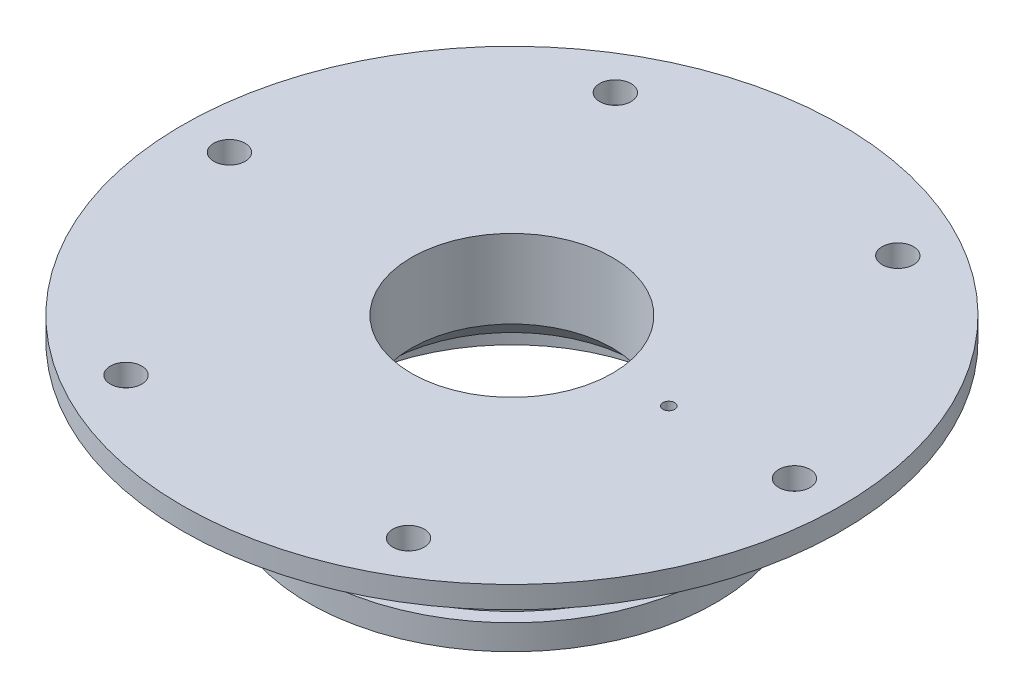
from build123d import *

# Parameters (mm, degrees)
SKETCH1_R                       = 66.675
SKETCH1_R_2                     = 20.32
BOSS_EXTRUDE1_DEPTH             = 4.445
F_1_4_0_25_DIAMETER_HOLE1_D     = 6.35
F_1_4_0_25_DIAMETER_HOLE1_DEPTH = 4.446
CIRPATTERN1_COUNT               = 6
SKETCH6_R                       = 41.148
SKETCH6_R_2                     = 20.32
BOSS_EXTRUDE2_DEPTH             = 25.4
SKETCH9_W                       = 2.9337
SKETCH9_H                       = 5.08
CIRPATTERN2_COUNT               = 6
F_3_32_0_09375_DIAMETER_HOLE1_D = 2.38125
SKETCH13_R                      = 34.925
CUT_EXTRUDE1_DEPTH              = 8.89
CHAMFER2_SIZE                   = 5.08


with BuildPart() as part:
    # Sketch1 → Boss-Extrude1 (new body)
    with BuildSketch(Plane(origin=(0, 0, 0), x_dir=(1, 0, 0), z_dir=(0, 1, 0))):
        Circle(SKETCH1_R)
        Circle(SKETCH1_R_2, mode=Mode.SUBTRACT)
    extrude(amount=BOSS_EXTRUDE1_DEPTH)

    # 1/4 (0.25) Diameter Hole1
    with Locations(Plane(origin=(0, 4.445, 0), x_dir=(1, 0, 0), z_dir=(0, 1, 0))):
        with Locations((57.15, 0)):
            f_1_4_0_25_diameter_hole1 = Hole(F_1_4_0_25_DIAMETER_HOLE1_D / 2, depth=F_1_4_0_25_DIAMETER_HOLE1_DEPTH)

    # CirPattern1: 1/4 (0.25) Diameter Hole1 ×6 about axis
    cirpattern1_axis = Axis((0, 0, 0), (0, 1, 0))
    for i in range(1, CIRPATTERN1_COUNT):
        add(f_1_4_0_25_diameter_hole1.rotate(cirpattern1_axis, i * 360 / CIRPATTERN1_COUNT), mode=Mode.SUBTRACT)

    # Sketch6 → Boss-Extrude2 (add)
    with BuildSketch(Plane.XZ):
        Circle(SKETCH6_R)
        Circle(SKETCH6_R_2, mode=Mode.SUBTRACT)
    extrude(amount=BOSS_EXTRUDE2_DEPTH)

    # Sketch9 → Cut-Revolve3 (revolve, cut)
    with BuildSketch(Plane.XY):
        with Locations((39.80815, -17.78)):
            Rectangle(SKETCH9_W, SKETCH9_H)
    revolve(axis=Axis((0, -0.47625, 0), (0, 1, 0)), mode=Mode.SUBTRACT)

    # Sketch10 → 1/4-20 Tapped Hole1 (revolve, cut)
    with BuildSketch(Plane(origin=(-35.635213315, -7.62, 20.574), x_dir=(0.5, 0, 0.866025404), z_dir=(0, 1, 0))):
        Polygon((0, 0), (0, 14.233816902), (2.5527, 12.7), (2.5527, 0), align=None)
    f_1_4_20_tapped_hole1 = revolve(axis=Axis((-41.134474629, -7.62, 23.749), (0.866025404, 0, -0.5)), mode=Mode.SUBTRACT)

    # CirPattern2: 1/4-20 Tapped Hole1 ×6 about axis
    cirpattern2_axis = Axis((0, -0.47625, 0), (0, 1, 0))
    for i in range(1, CIRPATTERN2_COUNT):
        add(f_1_4_20_tapped_hole1.rotate(cirpattern2_axis, i * 360 / CIRPATTERN2_COUNT), mode=Mode.SUBTRACT)

    # 3/32 (0.09375) Diameter Hole1 (through all)
    with Locations(Plane(origin=(0, 4.445, 0), x_dir=(1, 0, 0), z_dir=(0, 1, 0))):
        with Locations((31.75, 0)):
            Hole(F_3_32_0_09375_DIAMETER_HOLE1_D / 2)

    # Sketch13 → Cut-Extrude1 (cut)
    with BuildSketch(Plane.XZ.offset(25.4)):
        Circle(SKETCH13_R)
    extrude(amount=-CUT_EXTRUDE1_DEPTH, mode=Mode.SUBTRACT)

    # Chamfer2
    chamfer2_edges = [part.edges().sort_by_distance(p)[0] for p in [
        (-20.32, -16.51, 0),
    ]]
    chamfer(chamfer2_edges, length=CHAMFER2_SIZE)


solid = part.part
